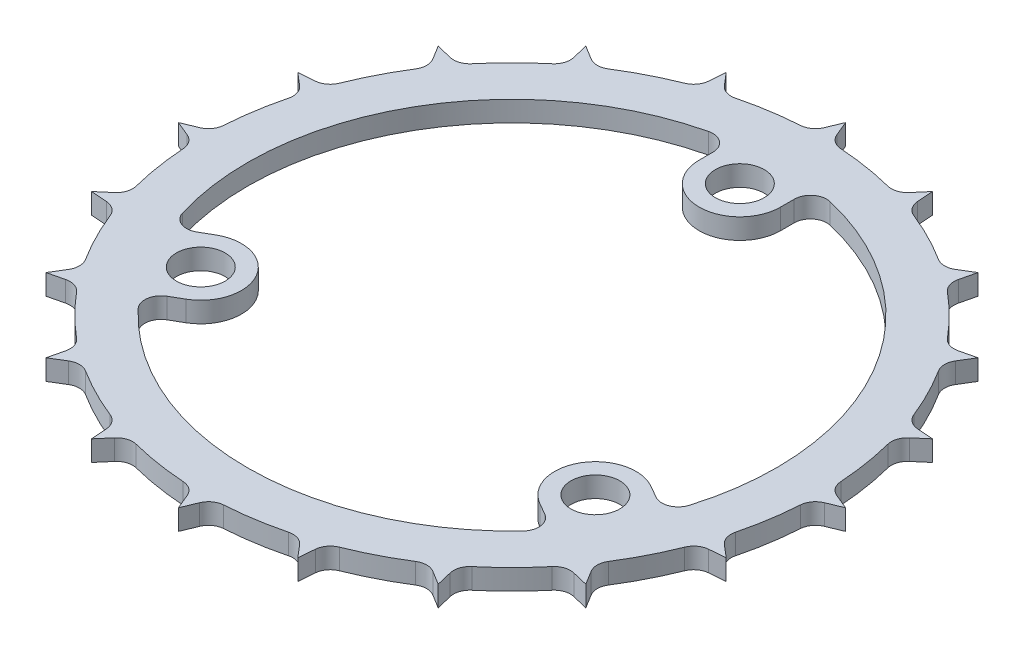
from build123d import *

# Parameters (mm, degrees)
SKETCH1_R                = 24.13
BOSS_EXTRUDE1_DEPTH      = 0.8001
BOSS_EXTRUDE2_DEPTH      = 1.6002
FILLET1_R                = 1.27
CIRPATTERN1_COUNT        = 20
FILLET1_OF_CIRPATTERN1_R = 1.27
SKETCH3_R                = 20.6375
CUT_EXTRUDE1_DEPTH       = 2.6002
SKETCH4_R                = 1.905
BOSS_EXTRUDE3_DEPTH      = 1.6002
FILLET2_R                = 1.27
CIRPATTERN2_COUNT        = 3
FILLET2_OF_CIRPATTERN2_R = 1.27


with BuildPart() as part:
    # Sketch1 → Boss-Extrude1 (new body, symmetric)
    with BuildSketch(Plane(origin=(0, 0, 0), x_dir=(1, 0, 0), z_dir=(0, 1, 0))):
        Circle(SKETCH1_R)
    extrude(amount=BOSS_EXTRUDE1_DEPTH, both=True)

    # Sketch2 → Boss-Extrude2 (add, through all)
    with BuildSketch(Plane(origin=(0, 0.8001, 0), x_dir=(1, 0, 0), z_dir=(0, 1, 0))):
        Polygon((-0.794496075, 24.116916801), (0, 26.035), (0.794496075, 24.116916801), align=None)
    boss_extrude2 = extrude(amount=-BOSS_EXTRUDE2_DEPTH)

    # Fillet1
    fillet1_edges = [part.edges().sort_by_distance(p)[0] for p in [
        (0.794496075, 0, -24.116916801),
        (-0.794496075, 0, -24.116916801),
    ]]
    fillet(fillet1_edges, radius=FILLET1_R)

    # CirPattern1: Boss-Extrude2 ×20 about axis
    cirpattern1_axis = Axis((0, 0, 0), (0, 1, 0))
    for i in range(1, CIRPATTERN1_COUNT):
        add(boss_extrude2.rotate(cirpattern1_axis, i * 360 / CIRPATTERN1_COUNT))

    # Fillet1 of CirPattern1
    fillet1_of_cirpattern1_edges = [part.edges().sort_by_distance(p)[0] for p in [
        (-6.696926474, 0, -23.182063666),
        (-8.208147813, 0, -22.691038087),
        (-13.5328072, 0, -19.97798862),
        (-14.818328853, 0, -19.044002468),
        (-19.044002468, 0, -14.818328853),
        (-19.97798862, 0, -13.5328072),
        (-22.691038087, 0, -8.208147813),
        (-23.182063666, 0, -6.696926474),
        (-24.116916801, 0, -0.794496075),
        (-24.116916801, 0, 0.794496075),
        (-23.182063666, 0, 6.696926474),
        (-22.691038087, 0, 8.208147813),
        (-19.97798862, 0, 13.5328072),
        (-19.044002468, 0, 14.818328853),
        (-14.818328853, 0, 19.044002468),
        (-13.5328072, 0, 19.97798862),
        (-8.208147813, 0, 22.691038087),
        (-6.696926474, 0, 23.182063666),
        (-0.794496075, 0, 24.116916801),
        (0.794496075, 0, 24.116916801),
        (6.696926474, 0, 23.182063666),
        (8.208147813, 0, 22.691038087),
        (13.5328072, 0, 19.97798862),
        (14.818328853, 0, 19.044002468),
        (19.044002468, 0, 14.818328853),
        (19.97798862, 0, 13.5328072),
        (22.691038087, 0, 8.208147813),
        (23.182063666, 0, 6.696926474),
        (24.116916801, 0, 0.794496075),
        (24.116916801, 0, -0.794496075),
        (23.182063666, 0, -6.696926474),
        (22.691038087, 0, -8.208147813),
        (19.97798862, 0, -13.5328072),
        (19.044002468, 0, -14.818328853),
        (14.818328853, 0, -19.044002468),
        (13.5328072, 0, -19.97798862),
        (8.208147813, 0, -22.691038087),
        (6.696926474, 0, -23.182063666),
    ]]
    fillet(fillet1_of_cirpattern1_edges, radius=FILLET1_OF_CIRPATTERN1_R)

    # Sketch3 → Cut-Extrude1 (cut, through all)
    with BuildSketch(Plane(origin=(0, 0.8001, 0), x_dir=(1, 0, 0), z_dir=(0, 1, 0))):
        Circle(SKETCH3_R)
    extrude(amount=-CUT_EXTRUDE1_DEPTH, mode=Mode.SUBTRACT)

    # Sketch4 → Boss-Extrude3 (add, through all)
    with BuildSketch(Plane(origin=(0, 0.8001, 0), x_dir=(1, 0, 0), z_dir=(0, 1, 0))):
        with BuildLine():
            Line((-3.175, 17.78), (-3.175, 20.391806719))
            ThreePointArc((-3.175, 20.391806719), (0, 20.6375), (3.175, 20.391806719))
            Line((3.175, 20.391806719), (3.175, 17.78))
            ThreePointArc((3.175, 17.78), (0, 14.605), (-3.175, 17.78))
        make_face()
        with Locations((0, 17.78)):
            Circle(SKETCH4_R, mode=Mode.SUBTRACT)
    boss_extrude3 = extrude(amount=-BOSS_EXTRUDE3_DEPTH)

    # Fillet2
    fillet2_edges = [part.edges().sort_by_distance(p)[0] for p in [
        (-3.175, 0, -20.391806719),
        (3.175, 0, -20.391806719),
    ]]
    fillet(fillet2_edges, radius=FILLET2_R)

    # CirPattern2: Boss-Extrude3 ×3 about axis
    cirpattern2_axis = Axis((0, 0, 0), (0, 1, 0))
    for i in range(1, CIRPATTERN2_COUNT):
        add(boss_extrude3.rotate(cirpattern2_axis, i * 360 / CIRPATTERN2_COUNT))

    # Fillet2 of CirPattern2
    fillet2_of_cirpattern2_edges = [part.edges().sort_by_distance(p)[0] for p in [
        (-16.072322647, 0, 12.945534016),
        (-19.247322647, 0, 7.446272702),
        (19.247322647, 0, 7.446272702),
        (16.072322647, 0, 12.945534016),
    ]]
    fillet(fillet2_of_cirpattern2_edges, radius=FILLET2_OF_CIRPATTERN2_R)


solid = part.part
